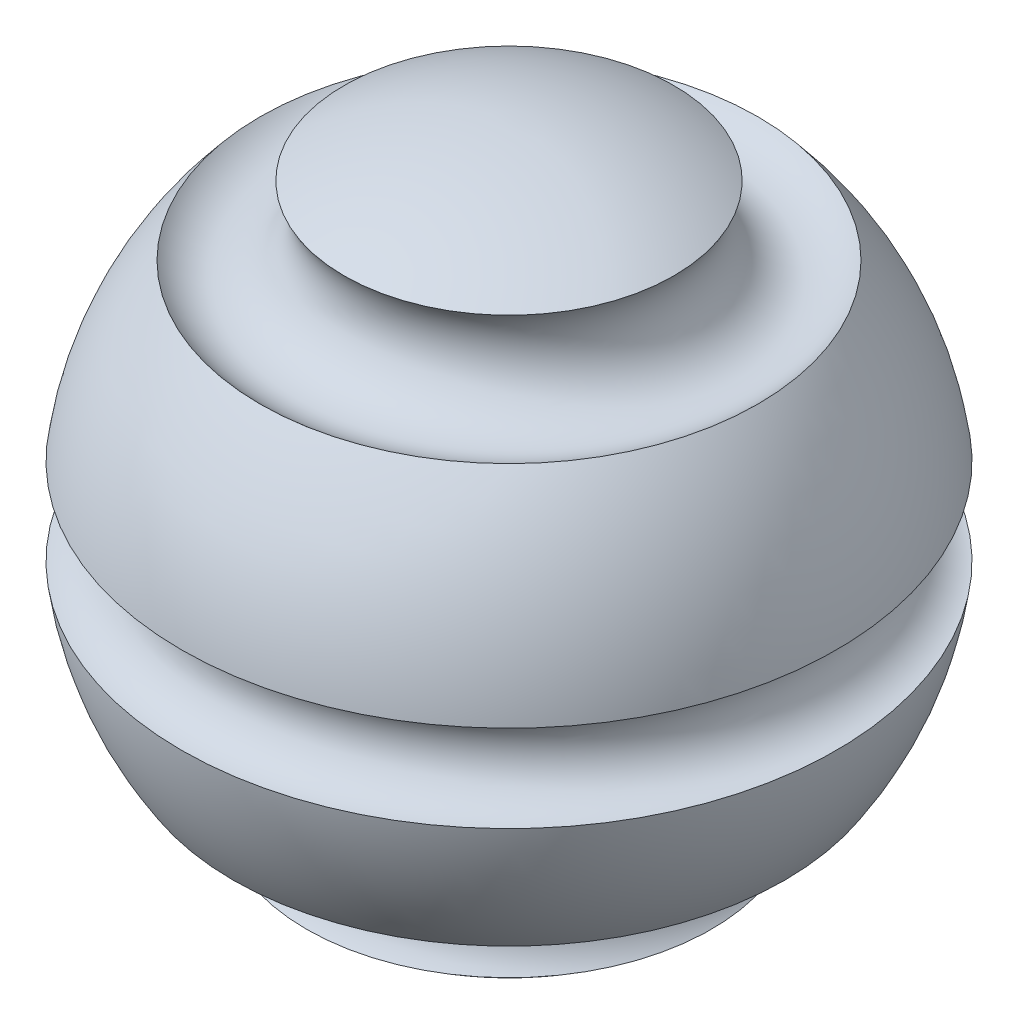
from build123d import *


with BuildPart() as part:
    # Sketch1 → Revolve1 (revolve)
    with BuildSketch(Plane.XY):
        with BuildLine():
            Line((0, 10), (0, -10))
            ThreePointArc((0, -10), (-3.238436543, -9.461106106), (-6.12783835, -7.902505751))
            ThreePointArc((-6.12783835, -7.902505751), (-6.133977344, -5.681757049), (-8.347760427, -5.505896462))
            ThreePointArc((-8.347760427, -5.505896462), (-9.367616987, -3.49967884), (-9.913002196, -1.316201905))
            ThreePointArc((-9.913002196, -1.316201905), (-8.680926055, 0), (-9.913002196, 1.316201905))
            ThreePointArc((-9.913002196, 1.316201905), (-9.111989111, 4.119666788), (-7.536362431, 6.57291726))
            ThreePointArc((-7.536362431, 6.57291726), (-5.30188183, 6.447929275), (-4.99273047, 8.664447037))
            ThreePointArc((-4.99273047, 8.664447037), (-2.584137151, 9.66034343), (0, 10))
        make_face()
    revolve(axis=Axis((0, 10, 0), (0, -1, 0)))


solid = part.part
